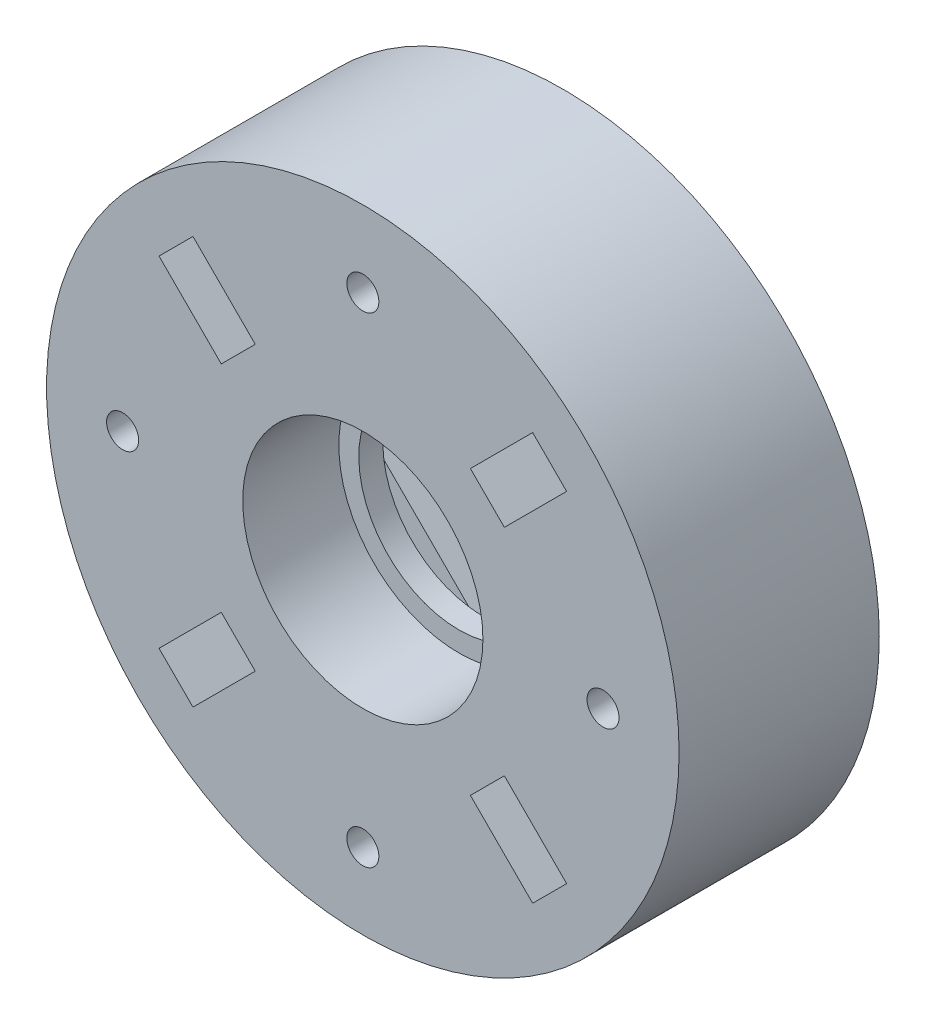
from build123d import *

# Parameters (mm, degrees)
CROQUIS1_R              = 39.5
CROQUIS1_R_2            = 12.5
CROQUIS1_R_3            = 2
SALIENTE_EXTRUIR1_DEPTH = 25
CROQUIS3_R              = 15
CORTAR_EXTRUIR1_DEPTH   = 12
CROQUIS5_R              = 16.857920318
SALIENTE_EXTRUIR2_DEPTH = 10
CROQUIS4_R              = 1.5
CORTAR_EXTRUIR2_DEPTH   = 10
CROQUIS6_R              = 1.5
CORTAR_EXTRUIR3_DEPTH   = 12


with BuildPart() as part:
    # Croquis1 → Saliente-Extruir1 (new body)
    with BuildSketch(Plane.XY):
        Circle(CROQUIS1_R)
        Circle(CROQUIS1_R_2, mode=Mode.SUBTRACT)
        with Locations((0, 30)):
            Circle(CROQUIS1_R_3, mode=Mode.SUBTRACT)
        with Locations((30, 0)):
            Circle(CROQUIS1_R_3, mode=Mode.SUBTRACT)
        with Locations((0, -30)):
            Circle(CROQUIS1_R_3, mode=Mode.SUBTRACT)
        with Locations((-30, 0)):
            Circle(CROQUIS1_R_3, mode=Mode.SUBTRACT)
    extrude(amount=SALIENTE_EXTRUIR1_DEPTH)

    # Croquis3 → Cortar-Extruir1 (cut)
    with BuildSketch(Plane.XY.offset(25)):
        Circle(CROQUIS3_R)
        Polygon((17.67766953, 13.435028843), (25.455844123, 21.213203436), (21.213203436, 25.455844123), (13.435028843, 17.67766953), align=None)
        Polygon((13.435028843, -17.67766953), (21.213203436, -25.455844123), (25.455844123, -21.213203436), (17.67766953, -13.435028843), align=None)
        Polygon((-17.67766953, -13.435028843), (-25.455844123, -21.213203436), (-21.213203436, -25.455844123), (-13.435028843, -17.67766953), align=None)
        Polygon((-13.435028843, 17.67766953), (-21.213203436, 25.455844123), (-25.455844123, 21.213203436), (-17.67766953, 13.435028843), align=None)
    extrude(amount=-CORTAR_EXTRUIR1_DEPTH, mode=Mode.SUBTRACT)

    # Croquis5 → Saliente-Extruir2 (add)
    with BuildSketch(Plane(origin=(0, 0, 0), x_dir=(-1, 0, 0), z_dir=(0, 0, -1))):
        Circle(CROQUIS5_R)
    extrude(amount=-SALIENTE_EXTRUIR2_DEPTH)

    # Croquis4 → Cortar-Extruir2 (cut)
    with BuildSketch(Plane(origin=(0, 0, 0), x_dir=(-1, 0, 0), z_dir=(0, 0, -1))):
        with Locations((-12.727922061, -6.363961031)):
            Circle(CROQUIS4_R)
        with Locations((-6.363961031, -12.727922061)):
            Circle(CROQUIS4_R)
        with Locations((21.920310217, 28.284271247)):
            Circle(CROQUIS4_R)
        with Locations((28.284271247, 21.920310217)):
            Circle(CROQUIS4_R)
        Polygon((30, -3.5), (33.031088913, -1.75), (33.031088913, 1.75), (30, 3.5), (26.968911087, 1.75), (26.968911087, -1.75), align=None)
        Polygon((3.5, 30), (1.75, 33.031088913), (-1.75, 33.031088913), (-3.5, 30), (-1.75, 26.968911087), (1.75, 26.968911087), align=None)
        Polygon((-3.5, -30), (-1.75, -33.031088913), (1.75, -33.031088913), (3.5, -30), (1.75, -26.968911087), (-1.75, -26.968911087), align=None)
        Polygon((-30, 3.5), (-33.031088913, 1.75), (-33.031088913, -1.75), (-30, -3.5), (-26.968911087, -1.75), (-26.968911087, 1.75), align=None)
        Polygon((0.353553391, -13.788582233), (29.344931419, 15.202795796), (15.202795796, 29.344931419), (-13.788582233, 0.353553391), align=None)
    extrude(amount=-CORTAR_EXTRUIR2_DEPTH, mode=Mode.SUBTRACT)

    # Croquis6 → Cortar-Extruir3 (cut)
    with BuildSketch(Plane(origin=(0, 0, 0), x_dir=(-1, 0, 0), z_dir=(0, 0, -1))):
        with Locations((-12.727922061, -6.363961031)):
            Circle(CROQUIS6_R)
        with Locations((-6.363961031, -12.727922061)):
            Circle(CROQUIS6_R)
        with Locations((21.920310217, 28.284271247)):
            Circle(CROQUIS6_R)
        with Locations((28.284271247, 21.920310217)):
            Circle(CROQUIS6_R)
    extrude(amount=-CORTAR_EXTRUIR3_DEPTH, mode=Mode.SUBTRACT)


solid = part.part
